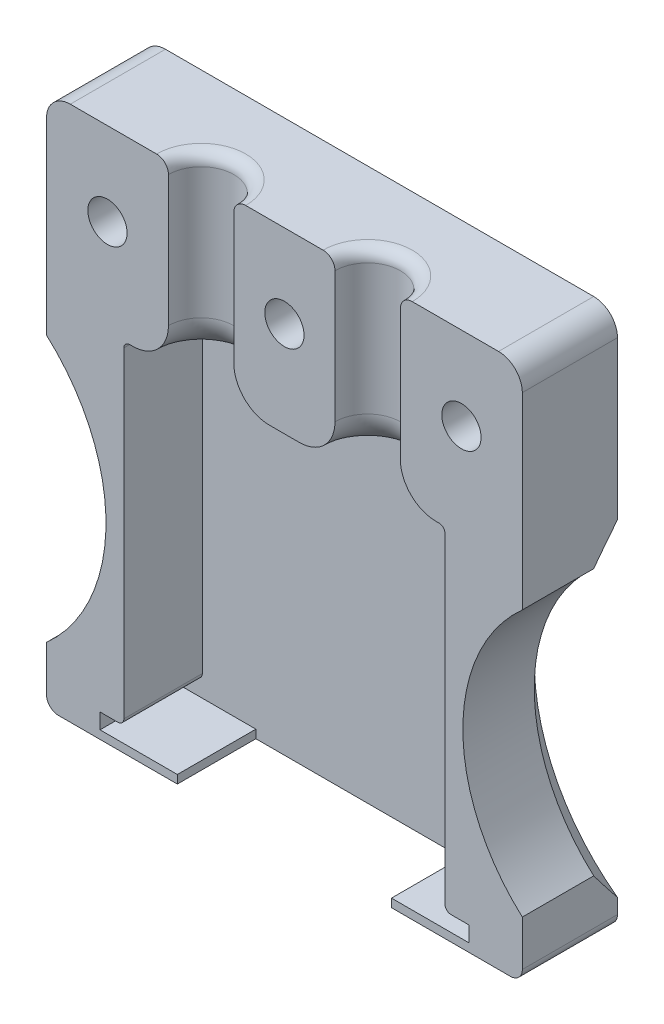
from build123d import *

# Parameters (mm, degrees)
CROQUIS1_W              = 40
CROQUIS1_H              = 45
SALIENTE_EXTRUIR1_DEPTH = 8
CROQUIS2_W              = 31
CROQUIS2_H              = 1.3
CORTAR_EXTRUIR1_DEPTH   = 6.6
CROQUIS3_R              = 15
CORTAR_EXTRUIR2_DEPTH   = 10
CHAFL_N1_SIZE           = 2
CROQUIS4_W              = 27
CROQUIS4_H              = 28
CORTAR_EXTRUIR3_DEPTH   = 6.6
CROQUIS6_R              = 2.75
CORTAR_EXTRUIR4_DEPTH   = 16.6
CROQUIS7_R              = 1.65
CORTAR_EXTRUIR5_DEPTH   = 16.6
CROQUIS8_R              = 4
CORTAR_EXTRUIR6_DEPTH   = 4
CROQUIS9_W              = 18
CROQUIS9_H              = 6.6
CORTAR_EXTRUIR7_DEPTH   = 4
REDONDEO1_R             = 1
REDONDEO2_R             = 2
REDONDEO3_R             = 1
REDONDEO4_R             = 3
REDONDEO5_R             = 0.5
REDONDEO6_R             = 0.5


with BuildPart() as part:
    # Croquis1 → Saliente-Extruir1 (new body)
    with BuildSketch(Plane.XY):
        Rectangle(CROQUIS1_W, CROQUIS1_H)
    extrude(amount=SALIENTE_EXTRUIR1_DEPTH)

    # Croquis2 → Cortar-Extruir1 (cut)
    with BuildSketch(Plane.XY.offset(8)):
        with Locations((0, -21.15)):
            Rectangle(CROQUIS2_W, CROQUIS2_H)
    extrude(amount=-CORTAR_EXTRUIR1_DEPTH, mode=Mode.SUBTRACT)

    # Croquis3 → Cortar-Extruir2 (cut)
    with BuildSketch(Plane.XY.offset(8)):
        with Locations((-30, -6.5)):
            Circle(CROQUIS3_R)
        with Locations((30, -6.5)):
            Circle(CROQUIS3_R)
    extrude(amount=-CORTAR_EXTRUIR2_DEPTH, mode=Mode.SUBTRACT)

    # Chaflán1
    chafl_n1_edges = [part.edges().sort_by_distance(p)[0] for p in [
        (-15, -6.5, 0),
        (15, -6.5, 0),
    ]]
    chamfer(chafl_n1_edges, length=CHAFL_N1_SIZE)

    # Croquis4 → Cortar-Extruir3 (cut)
    with BuildSketch(Plane.XY.offset(8)):
        with Locations((0, -6.5)):
            Rectangle(CROQUIS4_W, CROQUIS4_H)
    extrude(amount=-CORTAR_EXTRUIR3_DEPTH, mode=Mode.SUBTRACT)

    # Croquis6 → Cortar-Extruir4 (cut)
    with BuildSketch(Plane(origin=(0, 22.5, 0), x_dir=(1, 0, 0), z_dir=(0, 1, 0))):
        with Locations((7, -8)):
            Circle(CROQUIS6_R)
        with Locations((-7, -8)):
            Circle(CROQUIS6_R)
    extrude(amount=-CORTAR_EXTRUIR4_DEPTH, mode=Mode.SUBTRACT)

    # Croquis7 → Cortar-Extruir5 (cut)
    with BuildSketch(Plane.XY.offset(8)):
        with Locations((0, 15.5)):
            Circle(CROQUIS7_R)
        with Locations((14.88, 15.5)):
            Circle(CROQUIS7_R)
        with Locations((-14.875, 15.5)):
            Circle(CROQUIS7_R)
    extrude(amount=-CORTAR_EXTRUIR5_DEPTH, mode=Mode.SUBTRACT)

    # Croquis8 → Cortar-Extruir6 (cut)
    with BuildSketch(Plane(origin=(0, 0, 0), x_dir=(-1, 0, 0), z_dir=(0, 0, -1))):
        with Locations((14.875, 15.5)):
            Circle(CROQUIS8_R)
        with Locations((0, 15.5)):
            Circle(CROQUIS8_R)
        with Locations((-14.88, 15.5)):
            Circle(CROQUIS8_R)
    extrude(amount=-CORTAR_EXTRUIR6_DEPTH, mode=Mode.SUBTRACT)

    # Croquis9 → Cortar-Extruir7 (cut)
    with BuildSketch(Plane(origin=(0, -22.5, 0), x_dir=(-1, 0, 0), z_dir=(0, -1, 0))):
        with Locations((0, -4.7)):
            Rectangle(CROQUIS9_W, CROQUIS9_H)
    extrude(amount=-CORTAR_EXTRUIR7_DEPTH, mode=Mode.SUBTRACT)

    # Redondeo1
    redondeo1_edges = [part.edges().sort_by_distance(p)[0] for p in [
        (7, 22.5, 5.25),
        (-7, 22.5, 5.25),
    ]]
    fillet(redondeo1_edges, radius=REDONDEO1_R)

    # Redondeo2
    redondeo2_edges = [part.edges().sort_by_distance(p)[0] for p in [
        (-20, 22.5, 4),
        (20, 22.5, 4),
    ]]
    fillet(redondeo2_edges, radius=REDONDEO2_R)

    # Redondeo3
    redondeo3_edges = [part.edges().sort_by_distance(p)[0] for p in [
        (20, -22.5, 4),
        (-20, -22.5, 4),
    ]]
    fillet(redondeo3_edges, radius=REDONDEO3_R)

    # Redondeo4
    redondeo4_edges = [part.edges().sort_by_distance(p)[0] for p in [
        (7, 7.5, 5.25),
        (-7, 7.5, 5.25),
    ]]
    fillet(redondeo4_edges, radius=REDONDEO4_R)

    # Redondeo5
    redondeo5_edges = [part.edges().sort_by_distance(p)[0] for p in [
        (13.5, -20.5, 4.7),
        (-13.5, -20.5, 4.7),
    ]]
    fillet(redondeo5_edges, radius=REDONDEO5_R)

    # Redondeo6
    redondeo6_edges = [part.edges().sort_by_distance(p)[0] for p in [
        (-13.5, 7.5, 4.7),
        (13.5, 7.5, 4.7),
    ]]
    fillet(redondeo6_edges, radius=REDONDEO6_R)


solid = part.part
